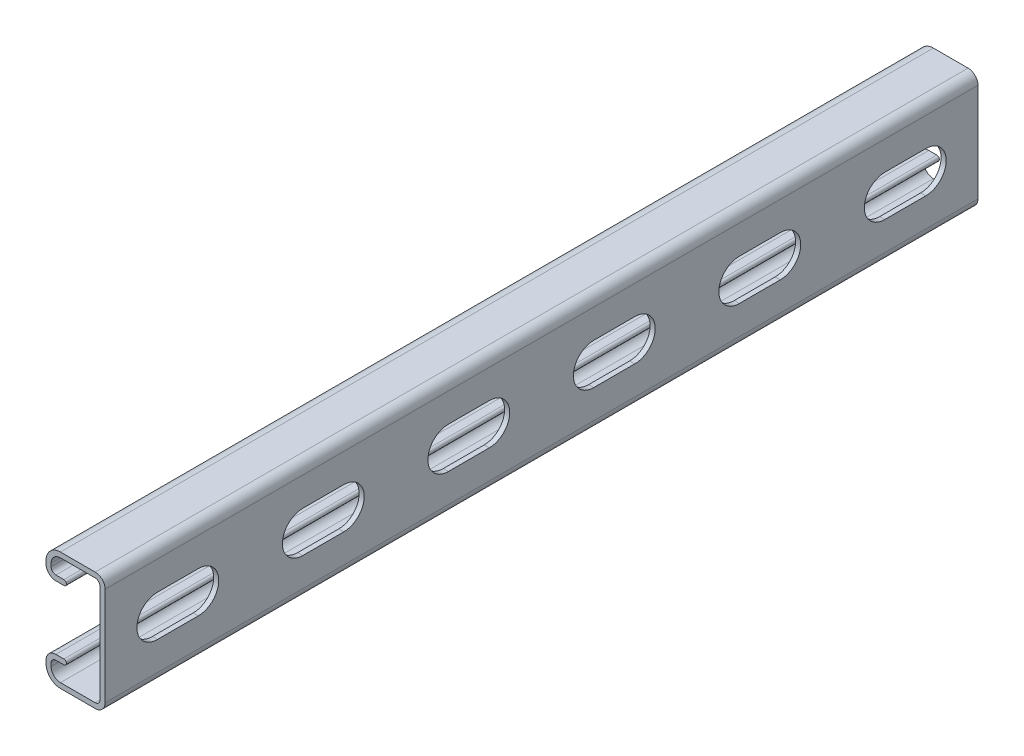
from build123d import *

# Parameters (mm, degrees)
BOSS_EXTRUDE1_DEPTH = 304.8
CUT_EXTRUDE1_DEPTH  = 1.778
LPATTERN1_COUNT     = 6
LPATTERN1_PITCH     = 50.8


with BuildPart() as part:
    # Sketch1 → Boss-Extrude1 (new body)
    with BuildSketch(Plane.XY):
        with BuildLine():
            Line((-15.58925, 20.6375), (-3.46075, 20.6375))
            ThreePointArc((-3.46075, 20.6375), (-1.013630207, 19.623869793), (0, 17.17675))
            Line((0, 17.17675), (0, -17.17675))
            ThreePointArc((0, -17.17675), (-1.013630207, -19.623869793), (-3.46075, -20.6375))
            Line((-3.46075, -20.6375), (-15.58925, -20.6375))
            ThreePointArc((-15.58925, -20.6375), (-19.158901808, -19.158901808), (-20.6375, -15.58925))
            Line((-20.6375, -15.58925), (-20.6375, -14.57325))
            ThreePointArc((-20.6375, -14.57325), (-19.623869793, -12.126130207), (-17.17675, -11.1125))
            Line((-17.17675, -11.1125), (-14.3891, -11.1125))
            ThreePointArc((-14.3891, -11.1125), (-13.5001, -12.0015), (-14.3891, -12.8905))
            Line((-14.3891, -12.8905), (-17.17675, -12.8905))
            ThreePointArc((-17.17675, -12.8905), (-18.366633936, -13.383366064), (-18.8595, -14.57325))
            Line((-18.8595, -14.57325), (-18.8595, -15.58925))
            ThreePointArc((-18.8595, -15.58925), (-17.901665951, -17.901665951), (-15.58925, -18.8595))
            Line((-15.58925, -18.8595), (-3.46075, -18.8595))
            ThreePointArc((-3.46075, -18.8595), (-2.270866064, -18.366633936), (-1.778, -17.17675))
            Line((-1.778, -17.17675), (-1.778, 17.17675))
            ThreePointArc((-1.778, 17.17675), (-2.270866064, 18.366633936), (-3.46075, 18.8595))
            Line((-3.46075, 18.8595), (-15.58925, 18.8595))
            ThreePointArc((-15.58925, 18.8595), (-17.901665951, 17.901665951), (-18.8595, 15.58925))
            Line((-18.8595, 15.58925), (-18.8595, 14.57325))
            ThreePointArc((-18.8595, 14.57325), (-18.366633936, 13.383366064), (-17.17675, 12.8905))
            Line((-17.17675, 12.8905), (-14.3891, 12.8905))
            ThreePointArc((-14.3891, 12.8905), (-13.5001, 12.0015), (-14.3891, 11.1125))
            Line((-14.3891, 11.1125), (-17.17675, 11.1125))
            ThreePointArc((-17.17675, 11.1125), (-19.623869793, 12.126130207), (-20.6375, 14.57325))
            Line((-20.6375, 14.57325), (-20.6375, 15.58925))
            ThreePointArc((-20.6375, 15.58925), (-19.158901808, 19.158901808), (-15.58925, 20.6375))
        make_face()
    extrude(amount=-BOSS_EXTRUDE1_DEPTH)

    # Sketch2 → Cut-Extrude1 (cut)
    with BuildSketch(Plane(origin=(0, 0, 0), x_dir=(0, 0, -1), z_dir=(1, 0, 0))):
        with BuildLine():
            Line((18.25625, 7.14375), (32.54375, 7.14375))
            ThreePointArc((32.54375, 7.14375), (39.6875, 0), (32.54375, -7.14375))
            Line((32.54375, -7.14375), (18.25625, -7.14375))
            ThreePointArc((18.25625, -7.14375), (11.1125, 0), (18.25625, 7.14375))
        make_face()
    cut_extrude1 = extrude(amount=-CUT_EXTRUDE1_DEPTH, mode=Mode.SUBTRACT)

    # LPattern1: Cut-Extrude1 ×6
    with Locations(*[(0, 0, -i * LPATTERN1_PITCH) for i in range(1, LPATTERN1_COUNT)]):
        add(cut_extrude1, mode=Mode.SUBTRACT)


solid = part.part
